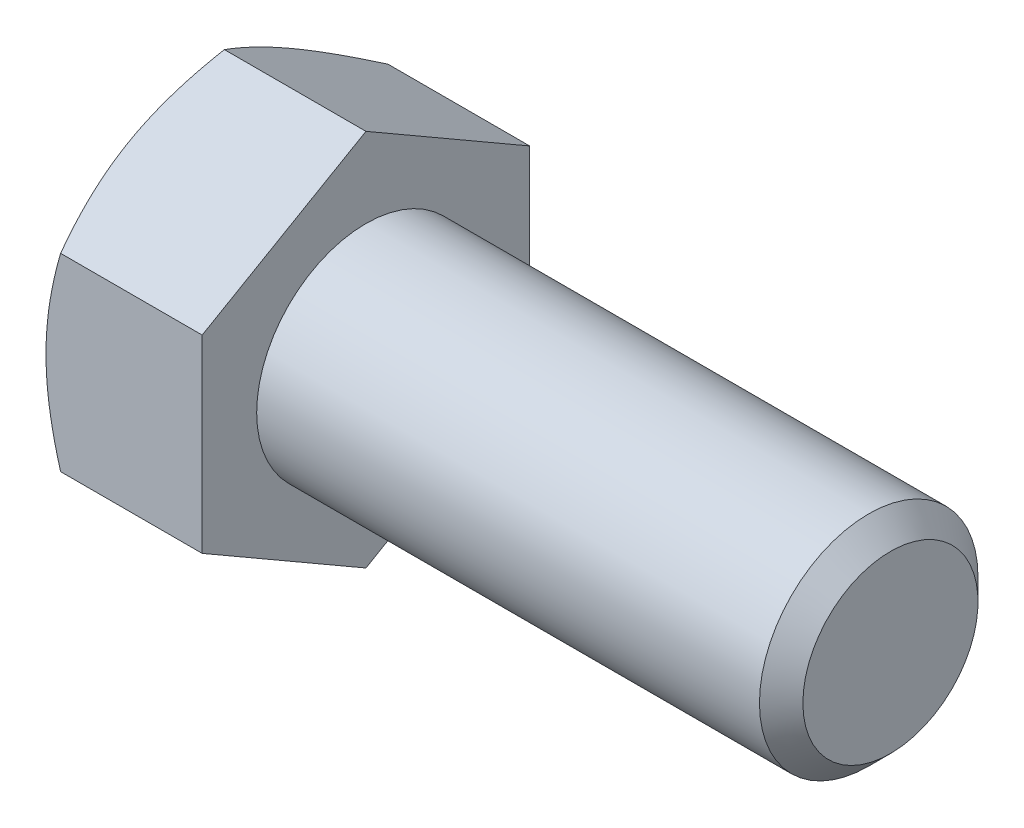
from build123d import *

# Parameters (mm, degrees)
BASEHEAD_DEPTH = 6.8072


with BuildPart() as part:
    # Sketch1 → BaseHead (new body)
    with BuildSketch(Plane(origin=(0, 0, 0), x_dir=(0, 0, -1), z_dir=(1, 0, 0))):
        Polygon((7.1374, 4.120779811), (7.1374, -4.120779811), (0, -8.241559623), (-7.1374, -4.120779811), (-7.1374, 4.120779811), (0, 8.241559623), align=None)
    extrude(amount=BASEHEAD_DEPTH)

    # BodySke → BaseBody (revolve)
    with BuildSketch(Plane.XY):
        Polygon((0, 0), (29.6672, 0), (29.6672, 3.81635), (28.72105, 4.7625), (0, 4.7625), align=None)
    revolve(axis=Axis((0, 0, 0), (1, 0, 0)))

    # Sketch3 → HeadChamfer (revolve, cut)
    with BuildSketch(Plane.XY):
        Polygon((0, 7.1374), (4.303661065, 14.591559623), (4.303661065, 20.941559623), (-12.7, 20.941559623), (-12.7, 7.1374), align=None)
    revolve(axis=Axis((0, 0, 0), (1, 0, 0)), mode=Mode.SUBTRACT)


solid = part.part
